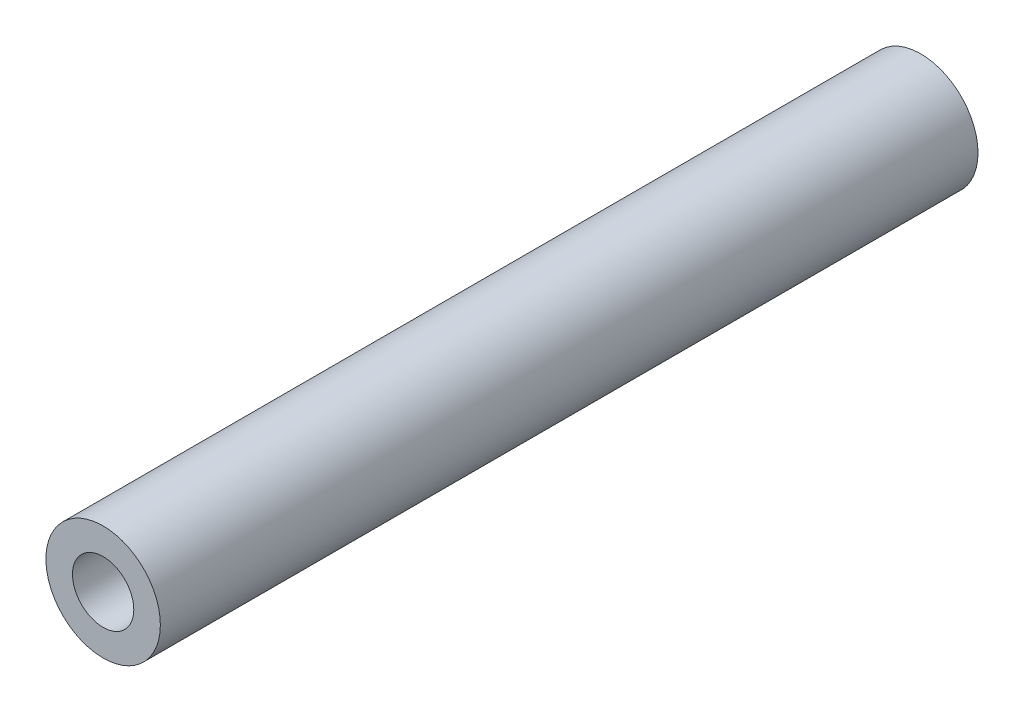
from build123d import *

# Parameters (mm, degrees)
SKETCH1_R           = 2.8
SKETCH1_R_2         = 1.5
BOSS_EXTRUDE1_DEPTH = 5
SKETCH2_R           = 2.8
BOSS_EXTRUDE2_DEPTH = 30
SKETCH3_R           = 2.8
SKETCH3_R_2         = 1.5
BOSS_EXTRUDE3_DEPTH = 5


with BuildPart() as part:
    # Sketch1 → Boss-Extrude1 (new body)
    with BuildSketch(Plane.XY):
        Circle(SKETCH1_R)
        Circle(SKETCH1_R_2, mode=Mode.SUBTRACT)
    extrude(amount=BOSS_EXTRUDE1_DEPTH)

    # Sketch2 → Boss-Extrude2 (add)
    with BuildSketch(Plane.XY.offset(5)):
        Circle(SKETCH2_R)
    extrude(amount=BOSS_EXTRUDE2_DEPTH)

    # Sketch3 → Boss-Extrude3 (add)
    with BuildSketch(Plane.XY.offset(35)):
        Circle(SKETCH3_R)
        Circle(SKETCH3_R_2, mode=Mode.SUBTRACT)
    extrude(amount=BOSS_EXTRUDE3_DEPTH)


solid = part.part
